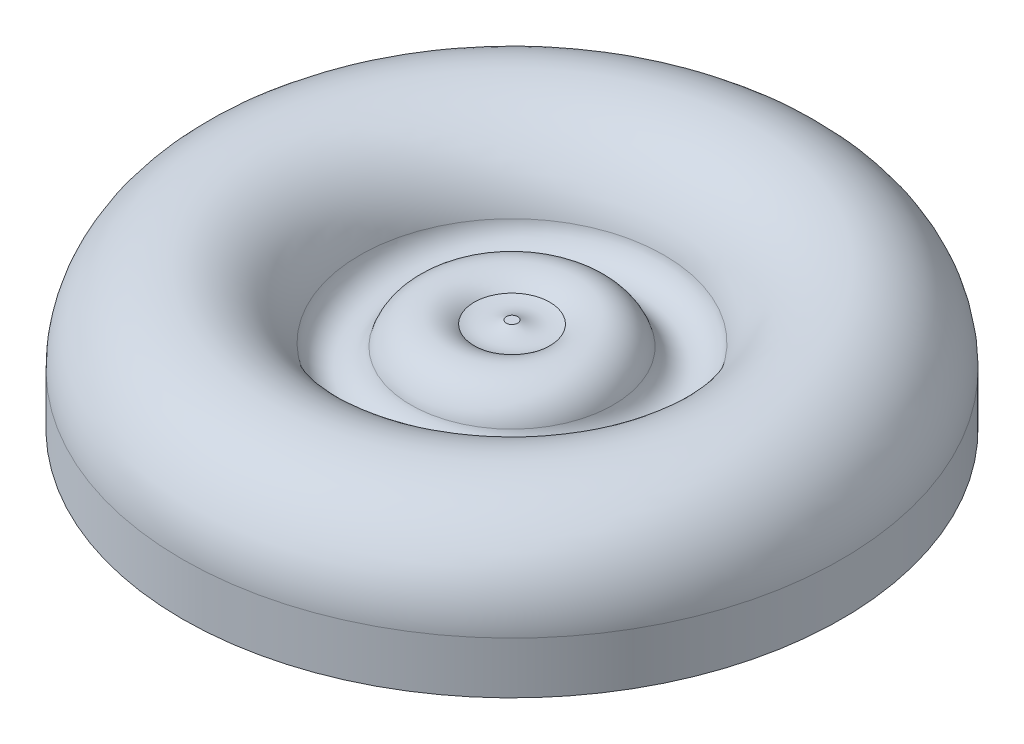
from build123d import *


with BuildPart() as part:
    # Sketch1 → Revolve1 (revolve)
    with BuildSketch(Plane.XY):
        with BuildLine():
            Line((0, 0), (0, 7.14024037))
            ThreePointArc((0, 7.14024037), (-10.863552097, 19.485230229), (-24.489599009, 10.279450287))
            ThreePointArc((-24.489599009, 10.279450287), (-27.821731607, 7.348582007), (-31.501935722, 9.82833889))
            ThreePointArc((-31.501935722, 9.82833889), (-35.138176859, 13.576179652), (-40.254364407, 12.530624802))
            ThreePointArc((-40.254364407, 12.530624802), (-42.51580515, 12.328830241), (-44.6786, 13.019593379))
            Line((-44.6786, 13.019593379), (-45.466, 13.019593379))
            Line((-45.466, 13.019593379), (-45.466, 0))
            Line((-45.466, 0), (0, 0))
        make_face()
    revolve(axis=Axis((-45.466, 0, 0), (0, 1, 0)))


solid = part.part
